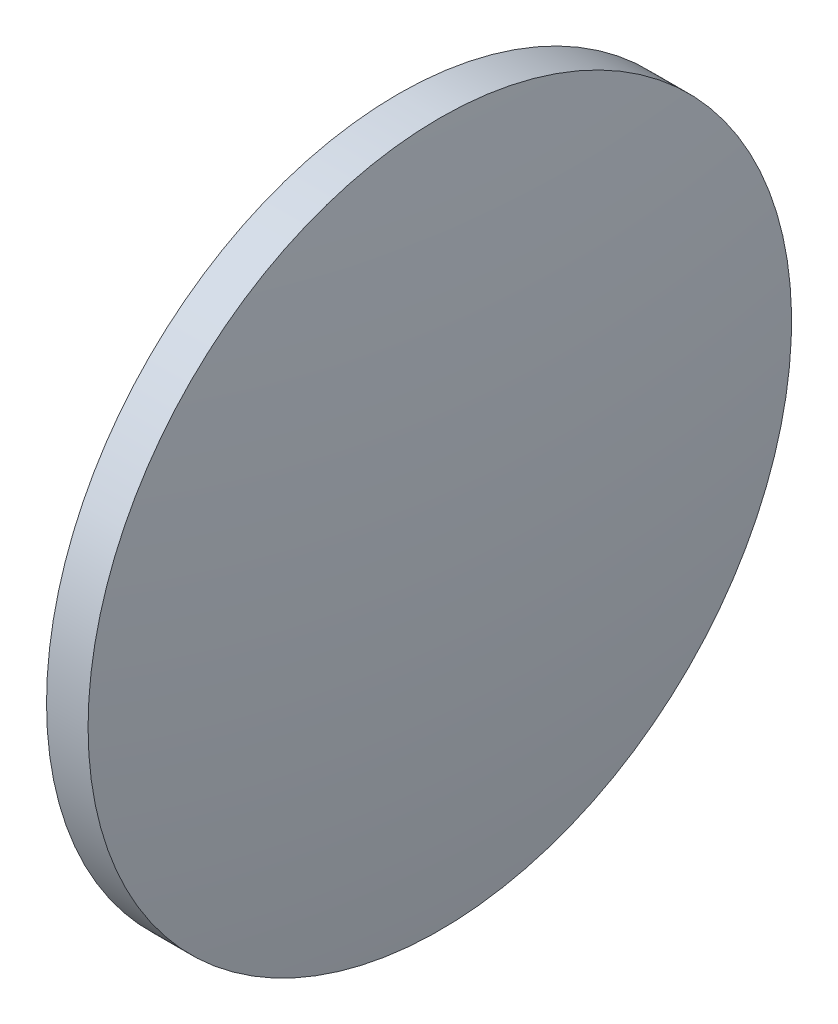
from build123d import *

# Parameters (mm, degrees)
SKETCH_1_ONE_SIDE_W = 2.999957714
SKETCH_1_ONE_SIDE_H = 25.4


with BuildPart() as part:
    # 草图1 one side → 旋转1 (revolve)
    with BuildSketch(Plane.XY):
        with Locations((172.916387549, 109.932226046)):
            Rectangle(SKETCH_1_ONE_SIDE_W, SKETCH_1_ONE_SIDE_H)
        with BuildLine():
            Line((169.666421264, 97.232226046), (171.416408692, 97.232226046))
            Line((171.416408692, 97.232226046), (171.416408692, 122.632226046))
            ThreePointArc((171.416408692, 122.632226046), (170.104436071, 109.962332645), (169.666421264, 97.232226046))
        make_face()
        with BuildLine():
            Line((174.416366406, 97.232226046), (176.166353835, 97.232226046))
            ThreePointArc((176.166353835, 97.232226046), (175.728339027, 109.962332645), (174.416366406, 122.632226046))
            Line((174.416366406, 122.632226046), (174.416366406, 97.232226046))
        make_face()
    revolve(axis=Axis((165.744107942, 97.232226046, 0), (1, 0, 0)))


solid = part.part
